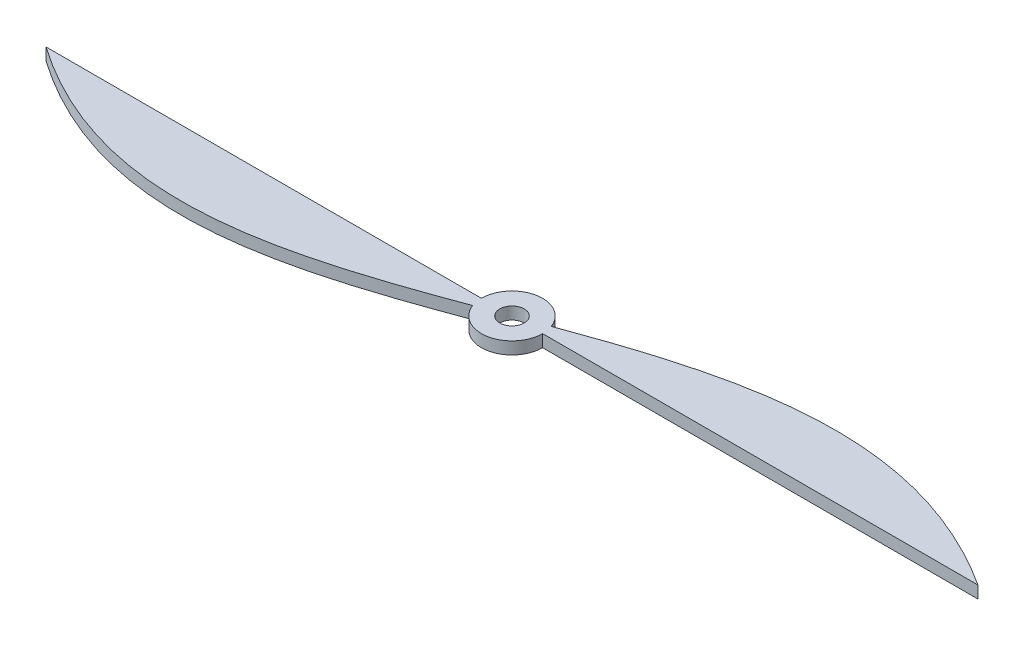
from build123d import *

# Parameters (mm, degrees)
ESQUISSE2_R        = 2
BOSS_EXTRU_1_DEPTH = 2


with BuildPart() as part:
    # Esquisse2 → Boss.-Extru.1 (new body)
    with BuildSketch(Plane(origin=(0, 0, 0), x_dir=(1, 0, 0), z_dir=(0, 1, 0))):
        with BuildLine():
            Line((5, 0), (76.2, 0))
            add(Edge.make_bspline(
                [(76.2, 0), (50.48496799, 16.589800369), (27.351766227, 10.012035882), (4.69008689, 1.732941131)],
                knots=[0.538892618, 0.538892618, 0.538892618, 0.538892618, 1, 1, 1, 1], degree=3))
            ThreePointArc((4.69008689, 1.732941131), (-0.880217459, 4.921911948), (-5, 0))
            Line((-5, 0), (-76.2, 0))
            add(Edge.make_bspline(
                [(-76.2, 0), (-51.013872042, -17.583290738), (-27.945849526, -10.334640761), (-4.686924988, -1.741474708)],
                knots=[0, 0, 0, 0, 0.475147649, 0.475147649, 0.475147649, 0.475147649], degree=3))
            ThreePointArc((-4.686924988, -1.741474708), (0.884696293, -4.921108866), (5, 0))
        make_face()
        Circle(ESQUISSE2_R, mode=Mode.SUBTRACT)
    extrude(amount=BOSS_EXTRU_1_DEPTH)


solid = part.part
